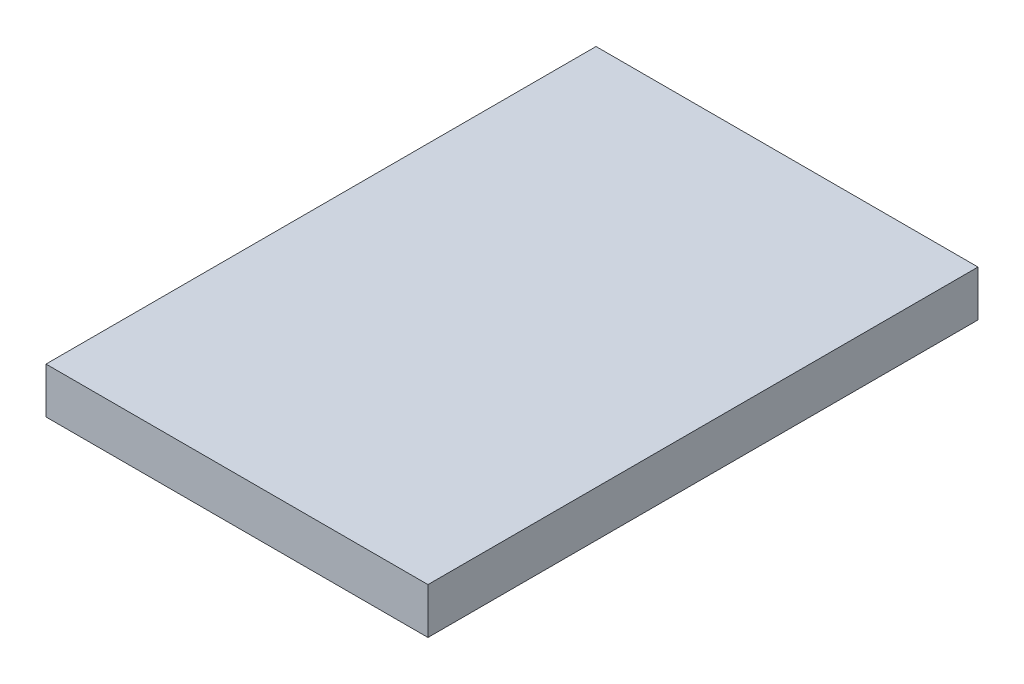
from build123d import *

# Parameters (mm, degrees)
SKETCH_1_W      = 25
SKETCH_1_H      = 36
EXTRUDE_1_DEPTH = 3


with BuildPart() as part:
    # 草图1 → 凸台-拉伸1 (new body)
    with BuildSketch(Plane(origin=(0, 0, 0), x_dir=(1, 0, 0), z_dir=(0, 1, 0))):
        Rectangle(SKETCH_1_W, SKETCH_1_H)
    extrude(amount=EXTRUDE_1_DEPTH)


solid = part.part
